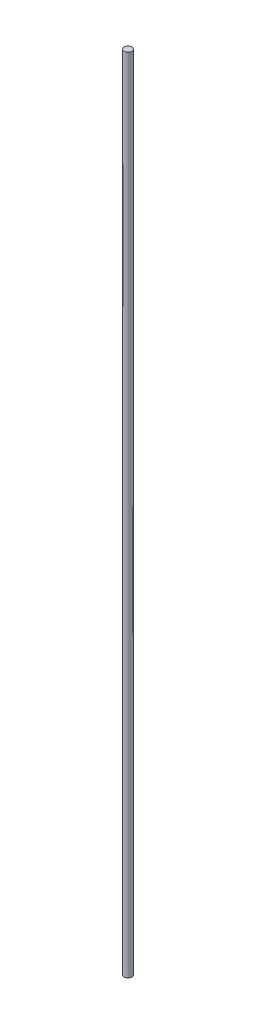
from build123d import *


with BuildPart() as part:
    # Sketch2 → Revolve1 (revolve)
    with BuildSketch(Plane.XY):
        Polygon((2.38125, 0), (2.38125, 500), (0, 500), (0, 1.5875), (0.79375, 1.5875), (0.79375, 0), align=None)
    revolve(axis=Axis((0, 1.5875, 0), (0, 1, 0)))


solid = part.part
